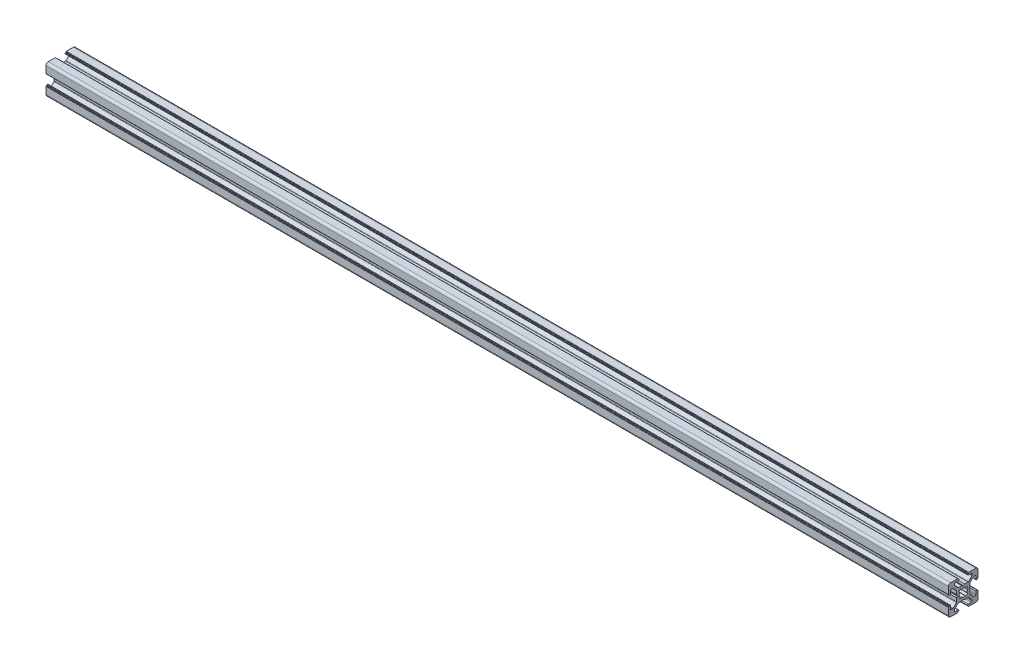
from build123d import *

# Parameters (mm, degrees)
T_SLOT_20X20_1_DEPTH = 611


with BuildPart() as part:
    # Sketch11 → T-slot 20X20(1) (new body)
    with BuildSketch(Plane.YZ):
        with BuildLine():
            Line((5.499785909, -8.498545991), (3.499785223, -8.498545991))
            ThreePointArc((3.499785223, -8.498545991), (3.146231832, -8.644992601), (2.999785223, -8.998545991))
            Line((2.999785223, -8.998545991), (2.999785223, -9.298545991))
            ThreePointArc((2.999785223, -9.298545991), (3.058363866, -9.439967347), (3.199785223, -9.498545991))
            Line((3.199785223, -9.498545991), (3.348917703, -9.498545991))
            ThreePointArc((3.348917703, -9.498545991), (3.490339059, -9.557124635), (3.548917703, -9.698545991))
            Line((3.548917703, -9.698545991), (3.548917703, -9.798898698))
            ThreePointArc((3.548917703, -9.798898698), (3.607496347, -9.940320055), (3.748917703, -9.998898698))
            Line((3.748917703, -9.998898698), (8.50021851, -9.998898698))
            ThreePointArc((8.50021851, -9.998898698), (9.560878681, -9.55955887), (10.00021851, -8.498898698))
            Line((10.00021851, -8.498898698), (10.00021851, -3.748917703))
            ThreePointArc((10.00021851, -3.748917703), (9.941639866, -3.607496347), (9.80021851, -3.548917703))
            Line((9.80021851, -3.548917703), (9.699407618, -3.548917703))
            ThreePointArc((9.699407618, -3.548917703), (9.557986262, -3.490339059), (9.499407618, -3.348917703))
            Line((9.499407618, -3.348917703), (9.499407618, -3.198545506))
            ThreePointArc((9.499407618, -3.198545506), (9.440828975, -3.05712415), (9.299407618, -2.998545506))
            Line((9.299407618, -2.998545506), (8.999407619, -2.998545506))
            ThreePointArc((8.999407619, -2.998545506), (8.645854228, -3.144992116), (8.499407619, -3.498545506))
            Line((8.499407619, -3.498545506), (8.499407619, -5.498575296))
            ThreePointArc((8.499407619, -5.498575296), (8.352961009, -5.852128686), (7.999407619, -5.998575295))
            Line((7.999407619, -5.998575295), (7.267164191, -5.998575295))
            ThreePointArc((7.267164191, -5.998575295), (7.075822118, -5.960514914), (6.913610254, -5.85212814))
            Line((6.913610254, -5.85212814), (4.64584686, -3.584357742))
            ThreePointArc((4.64584686, -3.584357742), (4.537460883, -3.422146257), (4.499400797, -3.230804897))
            Line((4.499400797, -3.230804897), (4.499400797, -0.952160718))
            ThreePointArc((4.499400797, -0.952160718), (4.492585963, -0.900396911), (4.47260588, -0.852160722))
            Line((4.47260588, -0.852160722), (4.037520883, -0.09857136))
            ThreePointArc((4.037520883, -0.09857136), (4.010725966, 0.001428635), (4.037520883, 0.101428631))
            Line((4.037520883, 0.101428631), (4.47260588, 0.855018004))
            ThreePointArc((4.47260588, 0.855018004), (4.492585963, 0.903254193), (4.499400797, 0.955017999))
            Line((4.499400797, 0.955017999), (4.499400797, 3.233299817))
            ThreePointArc((4.499400797, 3.233299817), (4.537461178, 3.42464189), (4.645847952, 3.586853754))
            Line((4.645847952, 3.586853754), (6.91361835, 5.854617148))
            ThreePointArc((6.91361835, 5.854617148), (7.075829835, 5.963003125), (7.267171195, 6.001063211))
            Line((7.267171195, 6.001063211), (7.999407619, 6.001063211))
            ThreePointArc((7.999407619, 6.001063211), (8.352961009, 5.854616602), (8.499407619, 5.501063211))
            Line((8.499407619, 5.501063211), (8.499407619, 3.500665018))
            ThreePointArc((8.499407619, 3.500665018), (8.645854228, 3.147111627), (8.999407619, 3.000665018))
            Line((8.999407619, 3.000665018), (9.299407618, 3.000665018))
            ThreePointArc((9.299407618, 3.000665018), (9.440828975, 3.059243661), (9.499407618, 3.200665018))
            Line((9.499407618, 3.200665018), (9.499407618, 3.348917703))
            ThreePointArc((9.499407618, 3.348917703), (9.557986262, 3.490339059), (9.699407618, 3.548917703))
            Line((9.699407618, 3.548917703), (9.80021851, 3.548917703))
            ThreePointArc((9.80021851, 3.548917703), (9.941639866, 3.607496347), (10.00021851, 3.748917703))
            Line((10.00021851, 3.748917703), (10.00021851, 8.498918098))
            ThreePointArc((10.00021851, 8.498918098), (9.560878681, 9.55957827), (8.50021851, 9.998918098))
            Line((8.50021851, 9.998918098), (3.748917703, 9.998918098))
            ThreePointArc((3.748917703, 9.998918098), (3.607496347, 9.940339455), (3.548917703, 9.798918098))
            Line((3.548917703, 9.798918098), (3.548917703, 9.701076618))
            ThreePointArc((3.548917703, 9.701076618), (3.490339059, 9.559655262), (3.348917703, 9.501076618))
            Line((3.348917703, 9.501076618), (3.199785223, 9.501076618))
            ThreePointArc((3.199785223, 9.501076618), (3.058363866, 9.442497974), (2.999785223, 9.301076618))
            Line((2.999785223, 9.301076618), (2.999785223, 9.001076618))
            ThreePointArc((2.999785223, 9.001076618), (3.146231832, 8.647523228), (3.499785223, 8.501076618))
            Line((3.499785223, 8.501076618), (5.499785909, 8.501076618))
            ThreePointArc((5.499785909, 8.501076618), (5.853339299, 8.354630009), (5.999785909, 8.001076618))
            Line((5.999785909, 8.001076618), (5.999785909, 7.269203309))
            ThreePointArc((5.999785909, 7.269203309), (5.961725527, 7.077861236), (5.853338753, 6.915649372))
            Line((5.853338753, 6.915649372), (3.585209085, 4.647526709))
            ThreePointArc((3.585209085, 4.647526709), (3.4229976, 4.539140732), (3.231656241, 4.501080646))
            Line((3.231656241, 4.501080646), (0.953012714, 4.501080646))
            ThreePointArc((0.953012714, 4.501080646), (0.901248907, 4.494265812), (0.853012718, 4.474285729))
            Line((0.853012718, 4.474285729), (0.099422452, 4.03920021))
            ThreePointArc((0.099422452, 4.03920021), (-0.000577544, 4.012405293), (-0.100577539, 4.03920021))
            Line((-0.100577539, 4.03920021), (-0.854167817, 4.47428573))
            ThreePointArc((-0.854167817, 4.47428573), (-0.902404006, 4.494265812), (-0.954167812, 4.501080646))
            Line((-0.954167812, 4.501080646), (-3.232459322, 4.501080646))
            ThreePointArc((-3.232459322, 4.501080646), (-3.423801395, 4.539141027), (-3.586013258, 4.647527801))
            Line((-3.586013258, 4.647527801), (-5.854146074, 6.915667622))
            ThreePointArc((-5.854146074, 6.915667622), (-5.962532052, 7.077879107), (-6.000592138, 7.269220467))
            Line((-6.000592138, 7.269220467), (-6.000592138, 8.001076618))
            ThreePointArc((-6.000592138, 8.001076618), (-5.854145528, 8.354630009), (-5.500592138, 8.501076618))
            Line((-5.500592138, 8.501076618), (-3.500232358, 8.501076618))
            ThreePointArc((-3.500232358, 8.501076618), (-3.146678968, 8.647523228), (-3.000232358, 9.001076618))
            Line((-3.000232358, 9.001076618), (-3.000232358, 9.301076618))
            ThreePointArc((-3.000232358, 9.301076618), (-3.058811002, 9.442497974), (-3.200232358, 9.501076618))
            Line((-3.200232358, 9.501076618), (-3.348917703, 9.501076618))
            ThreePointArc((-3.348917703, 9.501076618), (-3.490339059, 9.559655262), (-3.548917703, 9.701076618))
            Line((-3.548917703, 9.701076618), (-3.548917703, 9.798918098))
            ThreePointArc((-3.548917703, 9.798918098), (-3.607496347, 9.940339455), (-3.748917703, 9.998918098))
            Line((-3.748917703, 9.998918098), (-8.498466696, 9.998918098))
            ThreePointArc((-8.498466696, 9.998918098), (-9.559126868, 9.55957827), (-9.998466696, 8.498918098))
            Line((-9.998466696, 8.498918098), (-9.998466696, 3.748917703))
            ThreePointArc((-9.998466696, 3.748917703), (-9.939888052, 3.607496347), (-9.798466696, 3.548917703))
            Line((-9.798466696, 3.548917703), (-9.699890154, 3.548917703))
            ThreePointArc((-9.699890154, 3.548917703), (-9.558468798, 3.490339059), (-9.499890154, 3.348917703))
            Line((-9.499890154, 3.348917703), (-9.499890154, 3.200665018))
            ThreePointArc((-9.499890154, 3.200665018), (-9.441311511, 3.059243661), (-9.299890154, 3.000665018))
            Line((-9.299890154, 3.000665018), (-8.999890154, 3.000665018))
            ThreePointArc((-8.999890154, 3.000665018), (-8.646336764, 3.147111627), (-8.499890154, 3.500665018))
            Line((-8.499890154, 3.500665018), (-8.499890154, 5.501063211))
            ThreePointArc((-8.499890154, 5.501063211), (-8.353443545, 5.854616602), (-7.999890154, 6.001063211))
            Line((-7.999890154, 6.001063211), (-7.26792762, 6.001063211))
            ThreePointArc((-7.26792762, 6.001063211), (-7.076585548, 5.96300283), (-6.914373684, 5.854616056))
            Line((-6.914373684, 5.854616056), (-4.646707794, 3.586943162))
            ThreePointArc((-4.646707794, 3.586943162), (-4.538321817, 3.424731677), (-4.500261731, 3.233390317))
            Line((-4.500261731, 3.233390317), (-4.500261731, 0.955009441))
            ThreePointArc((-4.500261731, 0.955009441), (-4.493446896, 0.903245635), (-4.473466814, 0.855009445))
            Line((-4.473466814, 0.855009445), (-4.03838182, 0.101420088))
            ThreePointArc((-4.03838182, 0.101420088), (-4.011586903, 0.001420093), (-4.038381819, -0.098579903))
            Line((-4.038381819, -0.098579903), (-4.473466814, -0.852169272))
            ThreePointArc((-4.473466814, -0.852169272), (-4.493446897, -0.90040546), (-4.500261731, -0.952169266))
            Line((-4.500261731, -0.952169266), (-4.500261731, -3.230811901))
            ThreePointArc((-4.500261731, -3.230811901), (-4.538322112, -3.422153974), (-4.646708886, -3.584365838))
            Line((-4.646708886, -3.584365838), (-6.914479284, -5.852129232))
            ThreePointArc((-6.914479284, -5.852129232), (-7.076690769, -5.960515209), (-7.268032129, -5.998575295))
            Line((-7.268032129, -5.998575295), (-7.999890154, -5.998575295))
            ThreePointArc((-7.999890154, -5.998575295), (-8.353443545, -5.852128686), (-8.499890154, -5.498575295))
            Line((-8.499890154, -5.498575295), (-8.499890154, -3.498545506))
            ThreePointArc((-8.499890154, -3.498545506), (-8.646336764, -3.144992116), (-8.999890154, -2.998545506))
            Line((-8.999890154, -2.998545506), (-9.299890154, -2.998545506))
            ThreePointArc((-9.299890154, -2.998545506), (-9.441311511, -3.05712415), (-9.499890154, -3.198545506))
            Line((-9.499890154, -3.198545506), (-9.499890154, -3.348917703))
            ThreePointArc((-9.499890154, -3.348917703), (-9.558468798, -3.490339059), (-9.699890154, -3.548917703))
            Line((-9.699890154, -3.548917703), (-9.798466696, -3.548917703))
            ThreePointArc((-9.798466696, -3.548917703), (-9.939888052, -3.607496347), (-9.998466696, -3.748917703))
            Line((-9.998466696, -3.748917703), (-9.998466696, -8.498898698))
            ThreePointArc((-9.998466696, -8.498898698), (-9.559126868, -9.55955887), (-8.498466696, -9.998898698))
            Line((-8.498466696, -9.998898698), (-3.748917703, -9.998898698))
            ThreePointArc((-3.748917703, -9.998898698), (-3.607496347, -9.940320055), (-3.548917703, -9.798898698))
            Line((-3.548917703, -9.798898698), (-3.548917703, -9.698545991))
            ThreePointArc((-3.548917703, -9.698545991), (-3.490339059, -9.557124635), (-3.348917703, -9.498545991))
            Line((-3.348917703, -9.498545991), (-3.200232358, -9.498545991))
            ThreePointArc((-3.200232358, -9.498545991), (-3.058811002, -9.439967347), (-3.000232358, -9.298545991))
            Line((-3.000232358, -9.298545991), (-3.000232358, -8.998545991))
            ThreePointArc((-3.000232358, -8.998545991), (-3.146678968, -8.644992601), (-3.500232358, -8.498545991))
            Line((-3.500232358, -8.498545991), (-5.500592138, -8.498545991))
            ThreePointArc((-5.500592138, -8.498545991), (-5.854145528, -8.352099382), (-6.000592138, -7.998545991))
            Line((-6.000592138, -7.998545991), (-6.000592138, -7.266660688))
            ThreePointArc((-6.000592138, -7.266660688), (-5.962531756, -7.075318615), (-5.854144982, -6.913106751))
            Line((-5.854144982, -6.913106751), (-3.58639624, -4.645365013))
            ThreePointArc((-3.58639624, -4.645365013), (-3.424184755, -4.536979036), (-3.232843395, -4.49891895))
            Line((-3.232843395, -4.49891895), (-0.954199096, -4.49891895))
            ThreePointArc((-0.954199096, -4.49891895), (-0.90243529, -4.492104116), (-0.854199101, -4.472124033))
            Line((-0.854199101, -4.472124033), (-0.100608835, -4.037038514))
            ThreePointArc((-0.100608835, -4.037038514), (-0.00060884, -4.010243598), (0.099391156, -4.037038514))
            Line((0.099391156, -4.037038514), (0.852981433, -4.472124033))
            ThreePointArc((0.852981433, -4.472124033), (0.901217622, -4.492104116), (0.952981428, -4.49891895))
            Line((0.952981428, -4.49891895), (3.232022111, -4.49891895))
            ThreePointArc((3.232022111, -4.49891895), (3.423364184, -4.536979331), (3.585576047, -4.645366105))
            Line((3.585576047, -4.645366105), (5.853339845, -6.913136907))
            ThreePointArc((5.853339845, -6.913136907), (5.961725823, -7.075348392), (5.999785909, -7.266689752))
            Line((5.999785909, -7.266689752), (5.999785909, -7.998545991))
            ThreePointArc((5.999785909, -7.998545991), (5.853339299, -8.352099382), (5.499785909, -8.498545991))
        make_face()
        with BuildLine():
            Line((2.99144723, 1.909465981), (2.444531068, 1.257791687))
            ThreePointArc((2.444531068, 1.257791687), (2.749140242, -3.06e-07), (2.444530789, -1.257792231))
            Line((2.444530789, -1.257792231), (2.991447018, -1.909466314))
            ThreePointArc((2.991447018, -1.909466314), (2.511126206, -2.50780024), (1.913429408, -2.988913643))
            Line((1.913429408, -2.988913643), (1.257791806, -2.444531007))
            ThreePointArc((1.257791806, -2.444531007), (-3.06e-07, -2.749140242), (-1.25779235, -2.444530727))
            Line((-1.25779235, -2.444530727), (-1.913495818, -2.988871128))
            ThreePointArc((-1.913495818, -2.988871128), (-2.511154205, -2.507772203), (-2.99144723, -1.909465981))
            Line((-2.99144723, -1.909465981), (-2.444531068, -1.257791687))
            ThreePointArc((-2.444531068, -1.257791687), (-2.749140242, 3.06e-07), (-2.444530789, 1.257792231))
            Line((-2.444530789, 1.257792231), (-2.991447018, 1.909466314))
            ThreePointArc((-2.991447018, 1.909466314), (-2.511126206, 2.50780024), (-1.913429408, 2.988913643))
            Line((-1.913429408, 2.988913643), (-1.257791806, 2.444531007))
            ThreePointArc((-1.257791806, 2.444531007), (-4.0323e-05, 2.749140242), (1.257720096, 2.444567903))
            Line((1.257720096, 2.444567903), (1.91342974, 2.98891343))
            ThreePointArc((1.91342974, 2.98891343), (2.511126484, 2.507799961), (2.99144723, 1.909465981))
        make_face(mode=Mode.SUBTRACT)
    extrude(amount=T_SLOT_20X20_1_DEPTH)


solid = part.part
